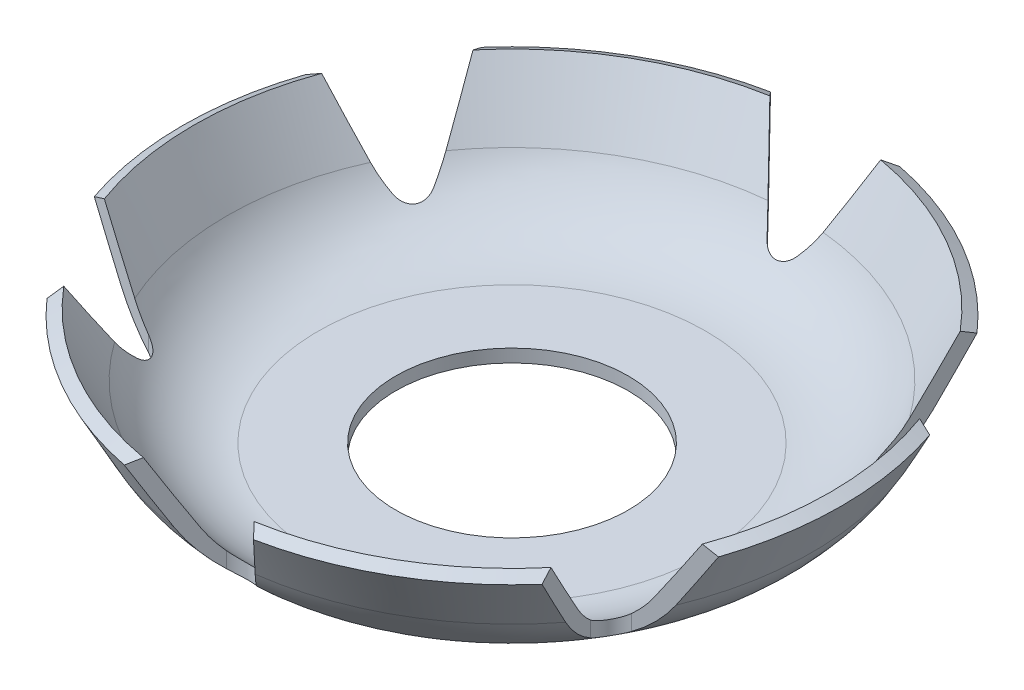
from build123d import *

# Parameters (mm, degrees)
ENL_V_START                  = -1
ENL_V_MAT_EXTRU_1_DEPTH      = 7
R_P_TITION_CIRCULAIRE1_COUNT = 6


with BuildPart() as part:
    # Esquisse2 → Révolution1 (revolve)
    with BuildSketch(Plane.XY, mode=Mode.PRIVATE) as r_volution1_sk:
        with BuildLine():
            Line((4.5, 0), (7.201056776, 0))
            ThreePointArc((7.201056776, 0), (9.766863159, 0.70853899), (11.605479997, 2.633344958))
            Line((11.605479997, 2.633344958), (12.75, 4.763334496))
            Line((12.75, 4.763334496), (12.309557678, 5))
            Line((12.309557678, 5), (11.023538577, 2.606675967))
            ThreePointArc((11.023538577, 2.606675967), (9.552645106, 1.066831192), (7.5, 0.5))
            Line((7.5, 0.5), (4.5, 0.5))
            Line((4.5, 0.5), (4.5, 0))
        make_face()
    revolve(r_volution1_sk.sketch.rotate(Axis((0, 0, 0), (0, 1, 0)), 90), axis=Axis((0, 0, 0), (0, 1, 0)))  # turned: the seam where the file's is

    # Esquisse3 → Enlèv. mat.-Extru.1 (cut)
    with BuildSketch(Plane(origin=(0, 0, 0), x_dir=(1, 0, 0), z_dir=(0, 1, 0)).offset(ENL_V_START)):
        with BuildLine():
            Line((-49.624128755, 62.90410991), (-2.5, 12.50249975))
            Line((-2.5, 12.50249975), (-0.584366138, 10.453633624))
            ThreePointArc((-0.584366138, 10.453633624), (0, 10.2), (0.584366138, 10.453633624))
            Line((0.584366138, 10.453633624), (2.5, 12.50249975))
            Line((2.5, 12.50249975), (49.624128755, 62.90410991))
            Line((49.624128755, 62.90410991), (49.624128755, 200.904194224))
            Line((49.624128755, 200.904194224), (-49.624128755, 200.904194224))
            Line((-49.624128755, 200.904194224), (-49.624128755, 62.90410991))
        make_face()
    enl_v_mat_extru_1 = extrude(amount=ENL_V_MAT_EXTRU_1_DEPTH, mode=Mode.SUBTRACT)

    # Répétition circulaire1: Enlèv. mat.-Extru.1 ×6 about axis
    r_p_tition_circulaire1_axis = Axis((0, 0, 0), (0, 1, 0))
    for i in range(1, R_P_TITION_CIRCULAIRE1_COUNT):
        add(enl_v_mat_extru_1.rotate(r_p_tition_circulaire1_axis, i * 360 / R_P_TITION_CIRCULAIRE1_COUNT), mode=Mode.SUBTRACT)


solid = part.part
